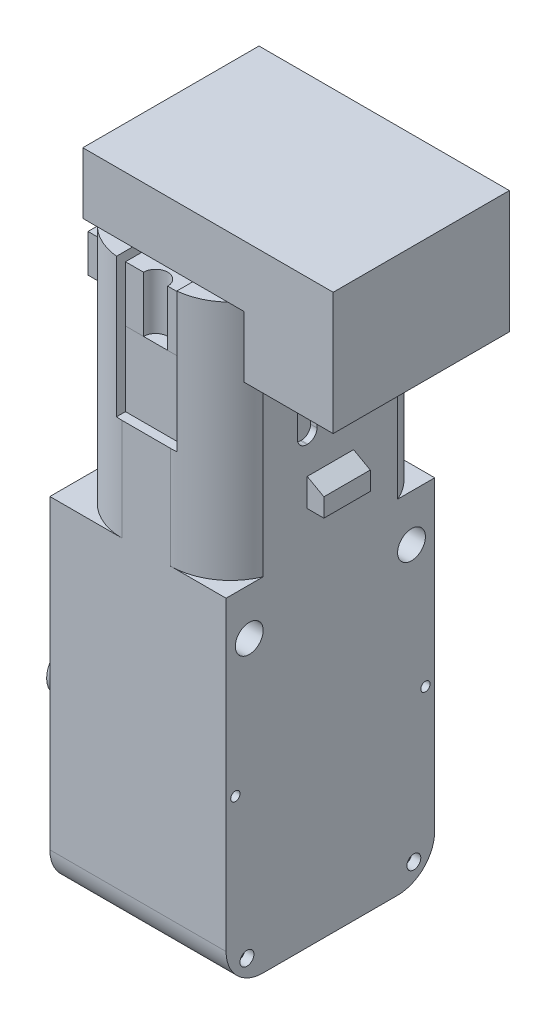
from build123d import *

# Parameters (mm, degrees)
SALIENTE_EXTRUIR2_DEPTH       = 9.5
SALIENTE_EXTRUIR2_DEPTH_BACK  = 9.5
SALIENTE_EXTRUIR4_DEPTH       = 1.3
SALIENTE_EXTRUIR4_DEPTH_BACK  = 1.3
CROQUIS2_R                    = 1.5
CROQUIS3_R                    = 2.5
CORTAR_EXTRUIR1_DEPTH         = 5
CROQUIS5_R                    = 0.75
CROQUIS5_R_2                  = 0.5
CORTAR_EXTRUIR2_DEPTH         = 1
CORTAR_EXTRUIR3_START         = -1
CROQUIS4_R                    = 0.5
CROQUIS4_R_2                  = 0.75
CORTAR_EXTRUIR3_DEPTH         = 1
CROQUIS6_R                    = 2
SALIENTE_EXTRUIR6_DEPTH       = 2
CROQUIS7_R                    = 1.5
CORTAR_EXTRUIR4_DEPTH         = 37.97672376
SALIENTE_EXTRUIR7_DEPTH       = 26
CROQUIS9_W                    = 27.483780483
CROQUIS9_H                    = 31.518144496
CORTAR_EXTRUIR5_DEPTH         = 60.879863894
CORTAR_EXTRUIR7_DEPTH         = 60.879863894
CORTAR_EXTRUIR7_DEPTH_BACK    = 60.879863894
CROQUIS11_W                   = 28.397068188
CROQUIS11_H                   = 15.296763251
CROQUIS12_W                   = 23.354698513
CROQUIS12_H                   = 7.169049234
CROQUIS12_R                   = 1.5
CORTAR_EXTRUIR8_DEPTH         = 60.879863894
CROQUIS14_W                   = 19
CROQUIS14_H                   = 22.5
SALIENTE_EXTRUIR9_DEPTH       = 30
CROQUIS15_R                   = 1.5
CORTAR_EXTRUIR9_DEPTH         = 60.879863894
CROQUIS16_R                   = 2
SALIENTE_EXTRUIR10_DEPTH      = 2
CROQUIS17_R                   = 0.5
CROQUIS17_R_2                 = 0.75
CORTAR_EXTRUIR10_DEPTH        = 60.879863894
CROQUIS20_W                   = 0.773109855
CROQUIS20_H                   = 0.470542453
SALIENTE_EXTRUIR12_DEPTH      = 24
CROQUIS21_W                   = 16.85701041
CROQUIS21_H                   = 22.5
SALIENTE_EXTRUIR13_DEPTH      = 24
CORTAR_EXTRUIR11_DEPTH        = 60.879863894
CROQUIS22_R                   = 2.6
CORTAR_EXTRUIR12_DEPTH        = 5
CROQUIS23_R                   = 2.75
CROQUIS23_R_2                 = 2.6
SALIENTE_EXTRUIR14_DEPTH      = 0.5
SALIENTE_EXTRUIR14_DRAFT      = 8
CROQUIS24_W                   = 2.5
CROQUIS24_H                   = 5
SALIENTE_EXTRUIR15_DEPTH      = 4.7
CROQUIS25_R                   = 1.4
CORTAR_EXTRUIR13_DEPTH        = 4.7
SALIENTE_EXTRUIR17_DEPTH      = 2
SALIENTE_EXTRUIR17_DEPTH_BACK = 19
CROQUIS26_W                   = 3
CROQUIS26_H                   = 5
CORTAR_EXTRUIR14_DEPTH        = 58.938312885
CORTAR_EXTRUIR14_DEPTH_BACK   = 58.938312885
CORTAR_EXTRUIR15_DEPTH        = 60.879863894
CORTAR_EXTRUIR16_START        = -7
CORTAR_EXTRUIR16_DEPTH        = 7
SALIENTE_EXTRUIR18_DEPTH      = 3.75
SALIENTE_EXTRUIR18_DEPTH_BACK = 3.75
CROQUIS30_W                   = 7.5
CROQUIS30_H                   = 1
CORTAR_EXTRUIR17_DEPTH        = 58.938312885
CORTAR_EXTRUIR17_DEPTH_BACK   = 58.938312885
CROQUIS31_W                   = 5.5
CROQUIS31_H                   = 1.5
CORTAR_EXTRUIR18_DEPTH        = 58.938312885
CORTAR_EXTRUIR18_DEPTH_BACK   = 58.938312885
CORTAR_EXTRUIR22_DEPTH        = 59.781677417
CORTAR_EXTRUIR22_DEPTH_BACK   = 59.781677417
CORTAR_EXTRUIR23_START        = -15
CORTAR_EXTRUIR23_DEPTH        = 15
CORTAR_EXTRUIR24_DEPTH        = 5
CROQUIS37_W                   = 15.777972317
CROQUIS37_H                   = 14.808381702
SALIENTE_EXTRUIR19_DEPTH      = 11
CROQUIS38_W                   = 18.88083152
CROQUIS38_H                   = 4.081408477
SALIENTE_EXTRUIR21_DEPTH      = 1
CROQUIS39_W                   = 9.12350037
CROQUIS39_H                   = 4.081408477
SALIENTE_EXTRUIR23_DEPTH      = 0.6
CROQUIS40_W                   = 6.5
CROQUIS40_H                   = 2
SALIENTE_EXTRUIR24_DEPTH      = 8
SALIENTE_EXTRUIR24_2_DEPTH    = 8
CROQUIS41_R                   = 1
SALIENTE_EXTRUIR26_DEPTH      = 7
SALIENTE_EXTRUIR27_DEPTH      = 6
SALIENTE_EXTRUIR27_2_DEPTH    = 6
SALIENTE_EXTRUIR28_DEPTH      = 6
CROQUIS44_W                   = 5.21443522
CROQUIS44_H                   = 9.574781913
SALIENTE_EXTRUIR29_DEPTH      = 2
CROQUIS46_R                   = 0.697640257
SALIENTE_EXTRUIR32_DEPTH      = 0.4
SALIENTE_EXTRUIR32_2_DEPTH    = 0.4
CROQUIS47_R                   = 2.6
SALIENTE_EXTRUIR33_DEPTH      = 14
CORTAR_EXTRUIR25_DEPTH        = 8
CROQUIS49_R                   = 1
CORTAR_EXTRUIR26_DEPTH        = 8
SKETCH_1_W                    = 27
SKETCH_1_H                    = 19
EXTRUDE_1_DEPTH               = 6.6
SKETCH_2_W                    = 9.618444136
SKETCH_2_H                    = 19
EXTRUDE_5_DEPTH               = 6.6


with BuildPart() as part:
    # Croquis1 → Saliente-Extruir2 (new, two sides: drawn at the far end of the back side and taken through both)
    with BuildSketch(Plane.YZ.offset(-SALIENTE_EXTRUIR2_DEPTH_BACK)):
        with BuildLine():
            Line((29.66, 11.25), (-4.84, 11.25))
            ThreePointArc((-4.84, 11.25), (-6.607766953, 10.517766953), (-7.34, 8.75))
            Line((-7.34, 8.75), (-7.34, -8.75))
            ThreePointArc((-7.34, -8.75), (-6.607766953, -10.517766953), (-4.84, -11.25))
            Line((-4.84, -11.25), (29.66, -11.25))
            Line((29.66, -11.25), (29.66, 11.25))
        make_face()
    extrude(amount=SALIENTE_EXTRUIR2_DEPTH + SALIENTE_EXTRUIR2_DEPTH_BACK)

    # Croquis2 → Saliente-Extruir4 (add, two sides: drawn at the far end of the back side and taken through both)
    with BuildSketch(Plane.YZ.offset(-SALIENTE_EXTRUIR4_DEPTH_BACK)):
        Polygon((-11.84, -1.34), (-11.84, -2.5), (-7.34, -2.5), (-7.34, 2.5), (-11.84, 2.5), (-11.84, 1.34), (-11.84, 0), align=None)
        with Locations((-9.34, 0)):
            Circle(CROQUIS2_R, mode=Mode.SUBTRACT)
    extrude(amount=SALIENTE_EXTRUIR4_DEPTH + SALIENTE_EXTRUIR4_DEPTH_BACK)

    # Croquis3 → Cortar-Extruir1 (cut)
    with BuildSketch(Plane(origin=(-9.5, 0, 0), x_dir=(0, -1, 0), z_dir=(-1, 0, 0))):
        Circle(CROQUIS3_R)
    extrude(amount=-CORTAR_EXTRUIR1_DEPTH, mode=Mode.SUBTRACT)

    # Croquis5 → Cortar-Extruir2 (cut)
    with BuildSketch(Plane.YZ.offset(9.5)):
        with Locations((-4.84, 8.75)):
            Circle(CROQUIS5_R)
        with Locations((5.66, 9.75)):
            Circle(CROQUIS5_R_2)
        with Locations((5.66, -9.75)):
            Circle(CROQUIS5_R_2)
        with Locations((-4.84, -8.75)):
            Circle(CROQUIS5_R)
    extrude(amount=-CORTAR_EXTRUIR2_DEPTH, mode=Mode.SUBTRACT)

    # Croquis4 → Cortar-Extruir3 (cut)
    with BuildSketch(Plane.ZY.offset(9.5).offset(CORTAR_EXTRUIR3_START)):
        with Locations((9.75, 5.66)):
            Circle(CROQUIS4_R)
        with Locations((8.75, -4.84)):
            Circle(CROQUIS4_R_2)
        with Locations((-9.75, 5.66)):
            Circle(CROQUIS4_R)
        with Locations((-8.75, -4.84)):
            Circle(CROQUIS4_R_2)
    extrude(amount=CORTAR_EXTRUIR3_DEPTH, mode=Mode.SUBTRACT)

    # Croquis6 → Saliente-Extruir6 (add)
    with BuildSketch(Plane.ZY.offset(9.5)):
        with Locations((0, 10.66)):
            Circle(CROQUIS6_R)
    extrude(amount=SALIENTE_EXTRUIR6_DEPTH)

    # Croquis7 → Cortar-Extruir4 (cut, through all)
    with BuildSketch(Plane.ZY.offset(9.5)):
        with Locations((-8.75, 19.66)):
            Circle(CROQUIS7_R)
        with Locations((8.75, 19.66)):
            Circle(CROQUIS7_R)
    extrude(amount=-CORTAR_EXTRUIR4_DEPTH, mode=Mode.SUBTRACT)

    # Croquis8 → Saliente-Extruir7 (add)
    with BuildSketch(Plane(origin=(0, 29.66, 0), x_dir=(-1, 0, 0), z_dir=(0, 1, 0))):
        with BuildLine():
            Line((1.7, 11.25), (-3.5, 11.25))
            ThreePointArc((-3.5, 11.25), (-7.105551275, 10.158326913), (-9.5, 7.25))
            Line((-9.5, 7.25), (-9.5, -7.25))
            ThreePointArc((-9.5, -7.25), (-7.105551275, -10.158326913), (-3.5, -11.25))
            Line((-3.5, -11.25), (1.7, -11.25))
            ThreePointArc((1.7, -11.25), (5.305551275, -10.158326913), (7.7, -7.25))
            Line((7.7, -7.25), (7.7, 7.25))
            ThreePointArc((7.7, 7.25), (5.305551275, 10.158326913), (1.7, 11.25))
        make_face()
    extrude(amount=SALIENTE_EXTRUIR7_DEPTH)

    # Croquis9 → Cortar-Extruir5 (cut, through all)
    with BuildSketch(Plane(origin=(-9.5, 0, 0), x_dir=(0, -1, 0), z_dir=(-1, 0, 0))):
        with Locations((5.081890242, -0.401551564)):
            Rectangle(CROQUIS9_W, CROQUIS9_H)
    extrude(amount=-CORTAR_EXTRUIR5_DEPTH, mode=Mode.SUBTRACT)

    # Croquis11 → Cortar-Extruir7 (cut, two sides: drawn at the far end of the back side and taken through both)
    with BuildSketch(Plane.ZY.offset(9.5).offset(-CORTAR_EXTRUIR7_DEPTH_BACK)):
        with Locations((-0.835139934, 10.44632309)):
            Rectangle(CROQUIS11_W, CROQUIS11_H)
    extrude(amount=CORTAR_EXTRUIR7_DEPTH + CORTAR_EXTRUIR7_DEPTH_BACK, mode=Mode.SUBTRACT)

    # Croquis12 → Cortar-Extruir8 (cut, through all)
    with BuildSketch(Plane.ZY.offset(9.5)):
        with Locations((0.427349257, 19.075475383)):
            Rectangle(CROQUIS12_W, CROQUIS12_H)
        with Locations((-8.75, 19.66)):
            Circle(CROQUIS12_R, mode=Mode.SUBTRACT)
        with Locations((8.75, 19.66)):
            Circle(CROQUIS12_R, mode=Mode.SUBTRACT)
    extrude(amount=-CORTAR_EXTRUIR8_DEPTH, mode=Mode.SUBTRACT)

    # Croquis14 → Saliente-Extruir9 (add)
    with BuildSketch(Plane(origin=(0, 22.66, 0), x_dir=(-1, 0, 0), z_dir=(0, -1, 0))):
        Rectangle(CROQUIS14_W, CROQUIS14_H)
    extrude(amount=SALIENTE_EXTRUIR9_DEPTH)

    # Croquis15 → Cortar-Extruir9 (cut, through all)
    with BuildSketch(Plane.ZY.offset(9.5)):
        with Locations((-8.75, 24.66)):
            Circle(CROQUIS15_R)
        with Locations((8.75, 24.66)):
            Circle(CROQUIS15_R)
    extrude(amount=-CORTAR_EXTRUIR9_DEPTH, mode=Mode.SUBTRACT)

    # Croquis16 → Saliente-Extruir10 (add)
    with BuildSketch(Plane.ZY.offset(9.5)):
        with Locations((0, 15.66)):
            Circle(CROQUIS16_R)
    extrude(amount=SALIENTE_EXTRUIR10_DEPTH)

    # Croquis17 → Cortar-Extruir10 (cut, through all)
    with BuildSketch(Plane.ZY.offset(9.5)):
        with Locations((10.25, 10.66)):
            Circle(CROQUIS17_R)
        with Locations((9, -5.09)):
            Circle(CROQUIS17_R_2)
        with Locations((-9, -5.09)):
            Circle(CROQUIS17_R_2)
        with Locations((-10.25, 10.66)):
            Circle(CROQUIS17_R)
    extrude(amount=-CORTAR_EXTRUIR10_DEPTH, mode=Mode.SUBTRACT)

    # Croquis20 → Saliente-Extruir12 (add)
    with BuildSketch(Plane.XZ.offset(7.34)):
        with Locations((2.429452283, 4.566914846)):
            Rectangle(CROQUIS20_W, CROQUIS20_H)
    extrude(amount=-SALIENTE_EXTRUIR12_DEPTH)

    # Croquis21 → Saliente-Extruir13 (add)
    with BuildSketch(Plane(origin=(0, -7.34, 0), x_dir=(-1, 0, 0), z_dir=(0, -1, 0))):
        with Locations((-0.10132468, 0)):
            Rectangle(CROQUIS21_W, CROQUIS21_H)
    extrude(amount=-SALIENTE_EXTRUIR13_DEPTH)

    # Croquis19 → Cortar-Extruir11 (cut, through all)
    with BuildSketch(Plane.ZY.offset(9.5)):
        with BuildLine():
            Line((7.25, -7.34), (11.25, -7.34))
            Line((11.25, -7.34), (11.25, -3.34))
            ThreePointArc((11.25, -3.34), (10.078427125, -6.168427125), (7.25, -7.34))
        make_face()
        with BuildLine():
            Line((-11.25, -7.34), (-7.25, -7.34))
            ThreePointArc((-7.25, -7.34), (-10.078427125, -6.168427125), (-11.25, -3.34))
            Line((-11.25, -3.34), (-11.25, -7.34))
        make_face()
    extrude(amount=-CORTAR_EXTRUIR11_DEPTH, mode=Mode.SUBTRACT)

    # Croquis22 → Cortar-Extruir12 (cut)
    with BuildSketch(Plane.ZY.offset(9.5)):
        with Locations((0, 3.86)):
            Circle(CROQUIS22_R)
    extrude(amount=-CORTAR_EXTRUIR12_DEPTH, mode=Mode.SUBTRACT)


with BuildPart() as saliente_extruir14_tool:
    # Croquis23 → Saliente-Extruir14 (with draft: the straight prism first)
    with BuildSketch(Plane.ZY.offset(9.5)):
        with Locations((0, 3.86)):
            Circle(CROQUIS23_R)
        with Locations((0, 3.86)):
            Circle(CROQUIS23_R_2, mode=Mode.SUBTRACT)
    extrude(amount=SALIENTE_EXTRUIR14_DEPTH)
    # Saliente-Extruir14: the draft: its side faces are tilted about the plane it starts from
    saliente_extruir14_sides = [saliente_extruir14_tool.faces().sort_by_distance(p)[0] for p in [
        (-9.75, 3.86, -2.75),
        (-9.75, 3.86, -2.6),
    ]]
    draft(saliente_extruir14_sides, Plane.ZY.offset(9.5), SALIENTE_EXTRUIR14_DRAFT)


with BuildPart() as part_1:
    add(part.part)

    # Saliente-Extruir14: add saliente_extruir14_tool
    add(saliente_extruir14_tool.part)

    # Croquis24 → Saliente-Extruir15 (add)
    with BuildSketch(Plane.XZ.offset(7.34)):
        Rectangle(CROQUIS24_W, CROQUIS24_H)
    extrude(amount=SALIENTE_EXTRUIR15_DEPTH)

    # Croquis25 → Cortar-Extruir13 (cut)
    with BuildSketch(Plane.ZY.offset(1.25)):
        with Locations((0, -9.64)):
            Circle(CROQUIS25_R)
    extrude(amount=-CORTAR_EXTRUIR13_DEPTH, mode=Mode.SUBTRACT)

    # Croquis26 → Saliente-Extruir17 (add, two sides: drawn at the far end of the back side and taken through both)
    with BuildSketch(Plane(origin=(-7.7, 0, 0), x_dir=(0, -1, 0), z_dir=(-1, 0, 0)).offset(-SALIENTE_EXTRUIR17_DEPTH_BACK)):
        with Locations((-35.16, 0)):
            Rectangle(CROQUIS26_W, CROQUIS26_H)
    extrude(amount=SALIENTE_EXTRUIR17_DEPTH + SALIENTE_EXTRUIR17_DEPTH_BACK)

    # Croquis27 → Cortar-Extruir14 (cut, two sides: drawn at the far end of the back side and taken through both)
    with BuildSketch(Plane(origin=(0, 0, 0), x_dir=(0, 1, 0), z_dir=(0, 0, 1)).offset(-CORTAR_EXTRUIR14_DEPTH_BACK)):
        Polygon((36.66, -9.5), (35.66, -11.3), (36.66, -11.3), align=None)
        Polygon((36.66, 9.7), (35.66, 9.7), (36.66, 7.7), align=None)
    extrude(amount=CORTAR_EXTRUIR14_DEPTH + CORTAR_EXTRUIR14_DEPTH_BACK, mode=Mode.SUBTRACT)

    # Croquis28 → Cortar-Extruir15 (cut, through all)
    with BuildSketch(Plane(origin=(-7.7, 0, 0), x_dir=(0, -1, 0), z_dir=(-1, 0, 0))):
        with BuildLine():
            Line((-40.66, -1.446465015), (-45.66, -1.446465015))
            ThreePointArc((-45.66, -1.446465015), (-46.367106781, -1.739358234), (-46.66, -2.446465015))
            Line((-46.66, -2.446465015), (-46.66, -2.553534985))
            ThreePointArc((-46.66, -2.553534985), (-46.367106781, -3.260641766), (-45.66, -3.553534985))
            Line((-45.66, -3.553534985), (-40.66, -3.553534985))
            ThreePointArc((-40.66, -3.553534985), (-39.952893219, -3.260641766), (-39.66, -2.553534985))
            Line((-39.66, -2.553534985), (-39.66, -2.446465015))
            ThreePointArc((-39.66, -2.446465015), (-39.952893219, -1.739358234), (-40.66, -1.446465015))
        make_face()
        with BuildLine():
            Line((-40.66, 3.553534985), (-45.66, 3.553534985))
            ThreePointArc((-45.66, 3.553534985), (-46.367106781, 3.260641766), (-46.66, 2.553534985))
            Line((-46.66, 2.553534985), (-46.66, 2.446465015))
            ThreePointArc((-46.66, 2.446465015), (-46.367106781, 1.739358234), (-45.66, 1.446465015))
            Line((-45.66, 1.446465015), (-40.66, 1.446465015))
            ThreePointArc((-40.66, 1.446465015), (-39.952893219, 1.739358234), (-39.66, 2.446465015))
            Line((-39.66, 2.446465015), (-39.66, 2.553534985))
            ThreePointArc((-39.66, 2.553534985), (-39.952893219, 3.260641766), (-40.66, 3.553534985))
        make_face()
    extrude(amount=-CORTAR_EXTRUIR15_DEPTH, mode=Mode.SUBTRACT)

    # Croquis29 → Cortar-Extruir16 (cut)
    with BuildSketch(Plane.YZ.offset(9.5).offset(CORTAR_EXTRUIR16_START)):
        with BuildLine():
            Line((50.66, -1.446465015), (45.66, -1.446465015))
            ThreePointArc((45.66, -1.446465015), (46.367106781, -1.739358234), (46.66, -2.446465015))
            Line((46.66, -2.446465015), (46.66, -2.553534985))
            ThreePointArc((46.66, -2.553534985), (46.367106781, -3.260641766), (45.66, -3.553534985))
            Line((45.66, -3.553534985), (50.66, -3.553534985))
            ThreePointArc((50.66, -3.553534985), (51.367106781, -3.260641766), (51.66, -2.553534985))
            Line((51.66, -2.553534985), (51.66, -2.446465015))
            ThreePointArc((51.66, -2.446465015), (51.367106781, -1.739358234), (50.66, -1.446465015))
        make_face()
        with BuildLine():
            Line((50.66, 3.553534985), (45.66, 3.553534985))
            ThreePointArc((45.66, 3.553534985), (46.367106781, 3.260641766), (46.66, 2.553534985))
            Line((46.66, 2.553534985), (46.66, 2.446465015))
            ThreePointArc((46.66, 2.446465015), (46.367106781, 1.739358234), (45.66, 1.446465015))
            Line((45.66, 1.446465015), (50.66, 1.446465015))
            ThreePointArc((50.66, 1.446465015), (51.367106781, 1.739358234), (51.66, 2.446465015))
            Line((51.66, 2.446465015), (51.66, 2.553534985))
            ThreePointArc((51.66, 2.553534985), (51.367106781, 3.260641766), (50.66, 3.553534985))
        make_face()
    extrude(amount=CORTAR_EXTRUIR16_DEPTH, mode=Mode.SUBTRACT)

    # Croquis30 → Saliente-Extruir18 (add, two sides: drawn at the far end of the back side and taken through both)
    with BuildSketch(Plane(origin=(0, 0, 0), x_dir=(0, 1, 0), z_dir=(0, 0, 1)).offset(-SALIENTE_EXTRUIR18_DEPTH_BACK)):
        with Locations((51.91, 8.2)):
            Rectangle(CROQUIS30_W, CROQUIS30_H)
    extrude(amount=SALIENTE_EXTRUIR18_DEPTH + SALIENTE_EXTRUIR18_DEPTH_BACK)

    # Croquis31 → Cortar-Extruir17 (cut, two sides: drawn at the far end of the back side and taken through both)
    with BuildSketch(Plane(origin=(0, 0, 0), x_dir=(0, 1, 0), z_dir=(0, 0, 1)).offset(-CORTAR_EXTRUIR17_DEPTH_BACK)):
        with Locations((51.91, 6.95)):
            Rectangle(CROQUIS31_W, CROQUIS31_H)
    extrude(amount=CORTAR_EXTRUIR17_DEPTH + CORTAR_EXTRUIR17_DEPTH_BACK, mode=Mode.SUBTRACT)

    # Croquis32 → Cortar-Extruir18 (cut, two sides: drawn at the far end of the back side and taken through both)
    with BuildSketch(Plane(origin=(0, 0, 0), x_dir=(0, 1, 0), z_dir=(0, 0, 1)).offset(-CORTAR_EXTRUIR18_DEPTH_BACK)):
        Polygon((48.16, 7.7), (48.16, 8.7), (48.926036623, 8.7), align=None)
    extrude(amount=CORTAR_EXTRUIR18_DEPTH + CORTAR_EXTRUIR18_DEPTH_BACK, mode=Mode.SUBTRACT)

    # Croquis33 → Cortar-Extruir22 (cut, two sides: drawn at the far end of the back side and taken through both)
    with BuildSketch(Plane.XY.offset(3.75).offset(-CORTAR_EXTRUIR22_DEPTH_BACK)):
        Polygon((-8.7, 55.386723755), (-7.7, 55.66), (-8.7, 55.66), align=None)
    extrude(amount=CORTAR_EXTRUIR22_DEPTH + CORTAR_EXTRUIR22_DEPTH_BACK, mode=Mode.SUBTRACT)

    # Croquis34 → Cortar-Extruir23 (cut)
    with BuildSketch(Plane(origin=(0, 55.66, 0), x_dir=(1, 0, 0), z_dir=(0, 1, 0)).offset(CORTAR_EXTRUIR23_START)):
        with BuildLine():
            Line((-1.7, -11.25), (3.5, -11.25))
            ThreePointArc((3.5, -11.25), (3.825408038, -11.241849475), (4.15, -11.217418341))
            Line((4.15, -11.217418341), (4.15, -8.25))
            Line((4.15, -8.25), (-2.35, -8.25))
            Line((-2.35, -8.25), (-2.35, -11.217418341))
            ThreePointArc((-2.35, -11.217418341), (-2.025408038, -11.241849475), (-1.7, -11.25))
        make_face()
        with BuildLine():
            ThreePointArc((4.15, 11.217418341), (3.825408038, 11.241849475), (3.5, 11.25))
            Line((3.5, 11.25), (-1.7, 11.25))
            ThreePointArc((-1.7, 11.25), (-2.025408038, 11.241849475), (-2.35, 11.217418341))
            Line((-2.35, 11.217418341), (-2.35, 8.25))
            Line((-2.35, 8.25), (4.15, 8.25))
            Line((4.15, 8.25), (4.15, 11.217418341))
        make_face()
    extrude(amount=CORTAR_EXTRUIR23_DEPTH, mode=Mode.SUBTRACT)

    # Croquis35 → Cortar-Extruir24 (cut)
    with BuildSketch(Plane(origin=(0, 55.66, 0), x_dir=(-1, 0, 0), z_dir=(0, 1, 0))):
        with BuildLine():
            ThreePointArc((3.1, 3), (-5.9, 0), (3.1, -3))
            Line((3.1, -3), (3.1, 3))
        make_face()
    extrude(amount=-CORTAR_EXTRUIR24_DEPTH, mode=Mode.SUBTRACT)



with BuildPart() as body_2:
    # Croquis37 → Saliente-Extruir19 (new body)
    with BuildSketch(Plane(origin=(0, 39.66, 0), x_dir=(1, 0, 0), z_dir=(0, 1, 0))):
        with Locations((0.922815991, 0.584105791)):
            Rectangle(CROQUIS37_W, CROQUIS37_H)
    extrude(amount=SALIENTE_EXTRUIR19_DEPTH)


with BuildPart() as body_3:
    # Croquis38 → Saliente-Extruir21 (new body)
    with BuildSketch(Plane.ZY.offset(6.2)):
        with Locations((0, 52.619295761)):
            Rectangle(CROQUIS38_W, CROQUIS38_H)
    extrude(amount=SALIENTE_EXTRUIR21_DEPTH)


with BuildPart() as body_4:
    # Croquis39 → Saliente-Extruir23 (new body)
    with BuildSketch(Plane.ZY.offset(7.2)):
        with Locations((-0.017583208, 52.619295761)):
            Rectangle(CROQUIS39_W, CROQUIS39_H)
    extrude(amount=SALIENTE_EXTRUIR23_DEPTH)


with BuildPart() as body_5:
    # Croquis40 → Saliente-Extruir24 (new body)
    with BuildSketch(Plane(origin=(0, 40.66, 0), x_dir=(-1, 0, 0), z_dir=(0, 1, 0))):
        with Locations((-0.9, -9.25)):
            Rectangle(CROQUIS40_W, CROQUIS40_H)
    extrude(amount=SALIENTE_EXTRUIR24_DEPTH)


with BuildPart() as body_6:
    # Croquis40 → Saliente-Extruir24 2 (new body)
    with BuildSketch(Plane(origin=(0, 40.66, 0), x_dir=(-1, 0, 0), z_dir=(0, 1, 0))):
        with Locations((-0.9, 9.25)):
            Rectangle(CROQUIS40_W, CROQUIS40_H)
    extrude(amount=SALIENTE_EXTRUIR24_2_DEPTH)


with BuildPart() as body_7:
    # Croquis41 → Saliente-Extruir26 (new body)
    with BuildSketch(Plane(origin=(0, 50.66, 0), x_dir=(1, 0, 0), z_dir=(0, 1, 0))):
        with Locations((0.9, 0)):
            Circle(CROQUIS41_R)
    extrude(amount=SALIENTE_EXTRUIR26_DEPTH)


with BuildPart() as body_8:
    # Croquis42 → Saliente-Extruir27 (new body)
    with BuildSketch(Plane(origin=(0, 48.66, 0), x_dir=(1, 0, 0), z_dir=(0, 1, 0))):
        with BuildLine():
            Line((4.15, -8.25), (-2.35, -8.25))
            Line((-2.35, -8.25), (-2.35, -10.25))
            Line((-2.35, -10.25), (-0.405896925, -10.25))
            ThreePointArc((-0.405896925, -10.25), (0.9, -8.944103075), (2.205896925, -10.25))
            Line((2.205896925, -10.25), (4.15, -10.25))
            Line((4.15, -10.25), (4.15, -8.25))
        make_face()
    extrude(amount=SALIENTE_EXTRUIR27_DEPTH)


with BuildPart() as body_9:
    # Croquis42 → Saliente-Extruir27 2 (new body)
    with BuildSketch(Plane(origin=(0, 48.66, 0), x_dir=(1, 0, 0), z_dir=(0, 1, 0))):
        with BuildLine():
            Line((4.15, 10.25), (2.205896925, 10.25))
            ThreePointArc((2.205896925, 10.25), (0.9, 8.944103075), (-0.405896925, 10.25))
            Line((-0.405896925, 10.25), (-2.35, 10.25))
            Line((-2.35, 10.25), (-2.35, 8.25))
            Line((-2.35, 8.25), (4.15, 8.25))
            Line((4.15, 8.25), (4.15, 10.25))
        make_face()
    extrude(amount=SALIENTE_EXTRUIR27_2_DEPTH)


with BuildPart() as body_10:
    # Croquis43 → Saliente-Extruir28 (new body)
    with BuildSketch(Plane(origin=(0, 50.66, 0), x_dir=(1, 0, 0), z_dir=(0, 1, 0))):
        with BuildLine():
            Line((-3.1, -3), (-3.1, 3))
            ThreePointArc((-3.1, 3), (5.9, 0), (-3.1, -3))
        make_face()
    extrude(amount=SALIENTE_EXTRUIR28_DEPTH)


with BuildPart() as body_11:
    # Croquis44 → Saliente-Extruir29 (new body)
    with BuildSketch(Plane(origin=(0, 50.66, 0), x_dir=(1, 0, 0), z_dir=(0, 1, 0))):
        with Locations((6.50794808, -0.067428042)):
            Rectangle(CROQUIS44_W, CROQUIS44_H)
    extrude(amount=SALIENTE_EXTRUIR29_DEPTH)


with BuildPart() as body_12:
    # Croquis46 → Saliente-Extruir32 (new body)
    with BuildSketch(Plane.ZY.offset(7.2)):
        with BuildLine():
            Line((8.197491621, 52.459588978), (8.197491621, 52.779002545))
            ThreePointArc((8.197491621, 52.779002545), (7.904598402, 53.486109326), (7.197491621, 53.779002545))
            Line((7.197491621, 53.779002545), (4.544166977, 53.779002545))
            Line((4.544166977, 53.779002545), (4.544166977, 51.459588978))
            Line((4.544166977, 51.459588978), (7.197491621, 51.459588978))
            ThreePointArc((7.197491621, 51.459588978), (7.904598402, 51.752482197), (8.197491621, 52.459588978))
        make_face()
        with Locations((7.197491621, 52.619295761)):
            Circle(CROQUIS46_R, mode=Mode.SUBTRACT)
    extrude(amount=SALIENTE_EXTRUIR32_DEPTH)


with BuildPart() as body_13:
    # Croquis46 → Saliente-Extruir32 2 (new body)
    with BuildSketch(Plane.ZY.offset(7.2)):
        with BuildLine():
            ThreePointArc((-7.197491621, 53.779002545), (-7.904598402, 53.486109326), (-8.197491621, 52.779002545))
            Line((-8.197491621, 52.779002545), (-8.197491621, 52.459588978))
            ThreePointArc((-8.197491621, 52.459588978), (-7.904598402, 51.752482197), (-7.197491621, 51.459588978))
            Line((-7.197491621, 51.459588978), (-4.544166977, 51.459588978))
            Line((-4.544166977, 51.459588978), (-4.544166977, 53.779002545))
            Line((-4.544166977, 53.779002545), (-7.197491621, 53.779002545))
        make_face()
        with Locations((-7.197491621, 52.619295761)):
            Circle(CROQUIS46_R, mode=Mode.SUBTRACT)
    extrude(amount=SALIENTE_EXTRUIR32_2_DEPTH)


with BuildPart() as body_14:
    # Croquis47 → Saliente-Extruir33 (new body)
    with BuildSketch(Plane.ZY.offset(4.5)):
        with Locations((0, 3.86)):
            Circle(CROQUIS47_R)
    extrude(amount=SALIENTE_EXTRUIR33_DEPTH)

    # Croquis48 → Cortar-Extruir25 (cut)
    with BuildSketch(Plane.ZY.offset(18.5)):
        with BuildLine():
            Line((-1.922888452, 5.61), (1.922888452, 5.61))
            ThreePointArc((1.922888452, 5.61), (0, 6.46), (-1.922888452, 5.61))
        make_face()
        with BuildLine():
            Line((1.922888452, 2.11), (-1.922888452, 2.11))
            ThreePointArc((-1.922888452, 2.11), (0, 1.26), (1.922888452, 2.11))
        make_face()
    extrude(amount=-CORTAR_EXTRUIR25_DEPTH, mode=Mode.SUBTRACT)

    # Croquis49 → Cortar-Extruir26 (cut)
    with BuildSketch(Plane.ZY.offset(18.5)):
        with Locations((0, 3.86)):
            Circle(CROQUIS49_R)
    extrude(amount=-CORTAR_EXTRUIR26_DEPTH, mode=Mode.SUBTRACT)


with BuildPart() as part_2:
    add(part_1.part)

    add(body_7.part)  # 填料-伸長1 merges body 7

    add(body_10.part)  # 填料-伸長1 merges body 10
    # 草圖1 → 填料-伸長1 (add)
    with BuildSketch(Plane(origin=(0, 55.66, 0), x_dir=(1, 0, 0), z_dir=(0, 1, 0))):
        with Locations((5.8, 0)):
            Rectangle(SKETCH_1_W, SKETCH_1_H)
    extrude(amount=EXTRUDE_1_DEPTH)

    # 草圖2 → 填料-伸長5 (add)
    with BuildSketch(Plane.XZ.offset(-55.66)):
        with Locations((14.490777932, 0)):
            Rectangle(SKETCH_2_W, SKETCH_2_H)
    extrude(amount=EXTRUDE_5_DEPTH)


solid = Compound([body_2.part, body_3.part, body_4.part, body_5.part, body_6.part, body_8.part, body_9.part, body_11.part, body_12.part, body_13.part, body_14.part, part_2.part])
